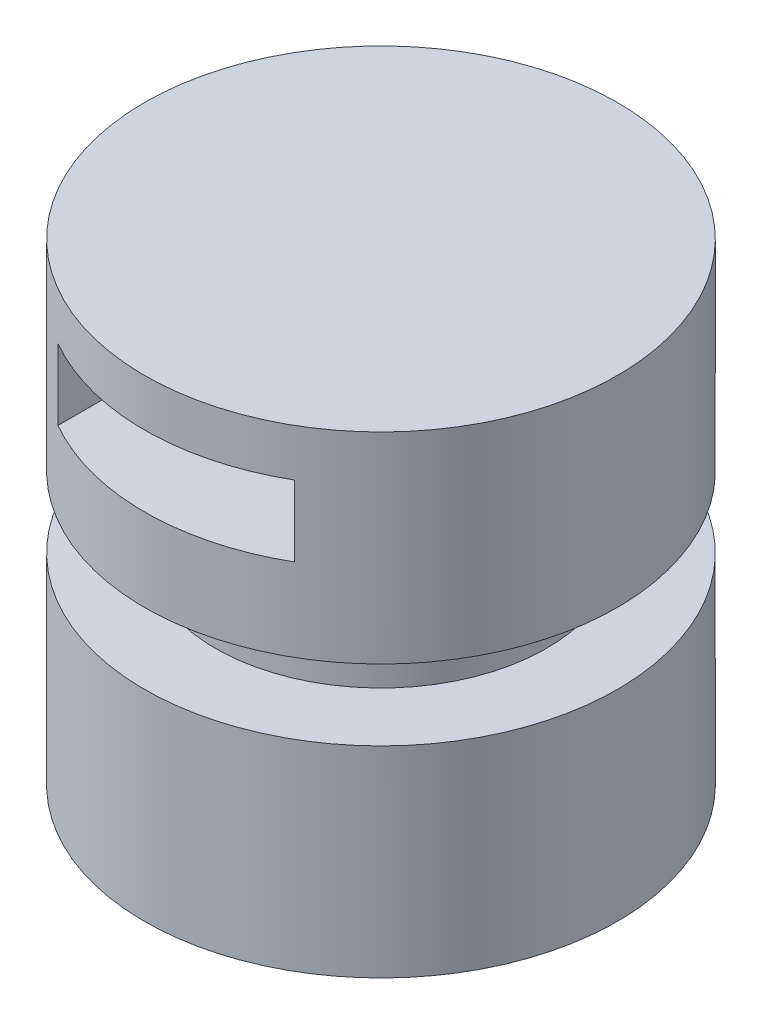
from build123d import *

# Parameters (mm, degrees)
SKETCH1_W               = 100
SKETCH1_H               = 200
SKETCH3_W               = 30
SKETCH3_H               = 30
SKETCH4_W               = 100
SKETCH4_H               = 30
CUT_EXTRUDE1_DEPTH      = 101
CUT_EXTRUDE1_DEPTH_BACK = 101


with BuildPart() as part:
    # Sketch1 → Revolve1 (revolve)
    with BuildSketch(Plane.XY):
        with Locations((50, 100)):
            Rectangle(SKETCH1_W, SKETCH1_H)
    revolve(axis=Axis((0, 200, 0), (0, -1, 0)))

    # Sketch3 → Cut-Revolve1 (revolve, cut)
    with BuildSketch(Plane(origin=(0, 0, 0), x_dir=(0, 0, -1), z_dir=(1, 0, 0))):
        with Locations((85, 100)):
            Rectangle(SKETCH3_W, SKETCH3_H)
    revolve(axis=Axis((0, 0, 0), (0, 1, 0)), mode=Mode.SUBTRACT)

    # Sketch4 → Cut-Extrude1 (cut, two sides)
    with BuildSketch(Plane.XY) as cut_extrude1_sk:
        with Locations((0, 165)):
            Rectangle(SKETCH4_W, SKETCH4_H)
    extrude(amount=CUT_EXTRUDE1_DEPTH, mode=Mode.SUBTRACT)
    extrude(cut_extrude1_sk.sketch, amount=-CUT_EXTRUDE1_DEPTH_BACK, mode=Mode.SUBTRACT)


solid = part.part
